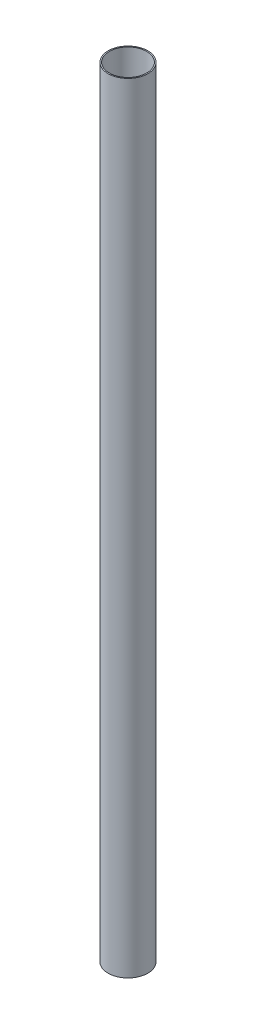
from build123d import *

# Parameters (mm, degrees)
SKETCH1_R           = 12.75
SKETCH1_R_2         = 12
BOSS_EXTRUDE1_DEPTH = 500


with BuildPart() as part:
    # Sketch1 → Boss-Extrude1 (new body)
    with BuildSketch(Plane(origin=(0, 0, 0), x_dir=(1, 0, 0), z_dir=(0, 1, 0))):
        Circle(SKETCH1_R)
        Circle(SKETCH1_R_2, mode=Mode.SUBTRACT)
    extrude(amount=BOSS_EXTRUDE1_DEPTH)


solid = part.part
